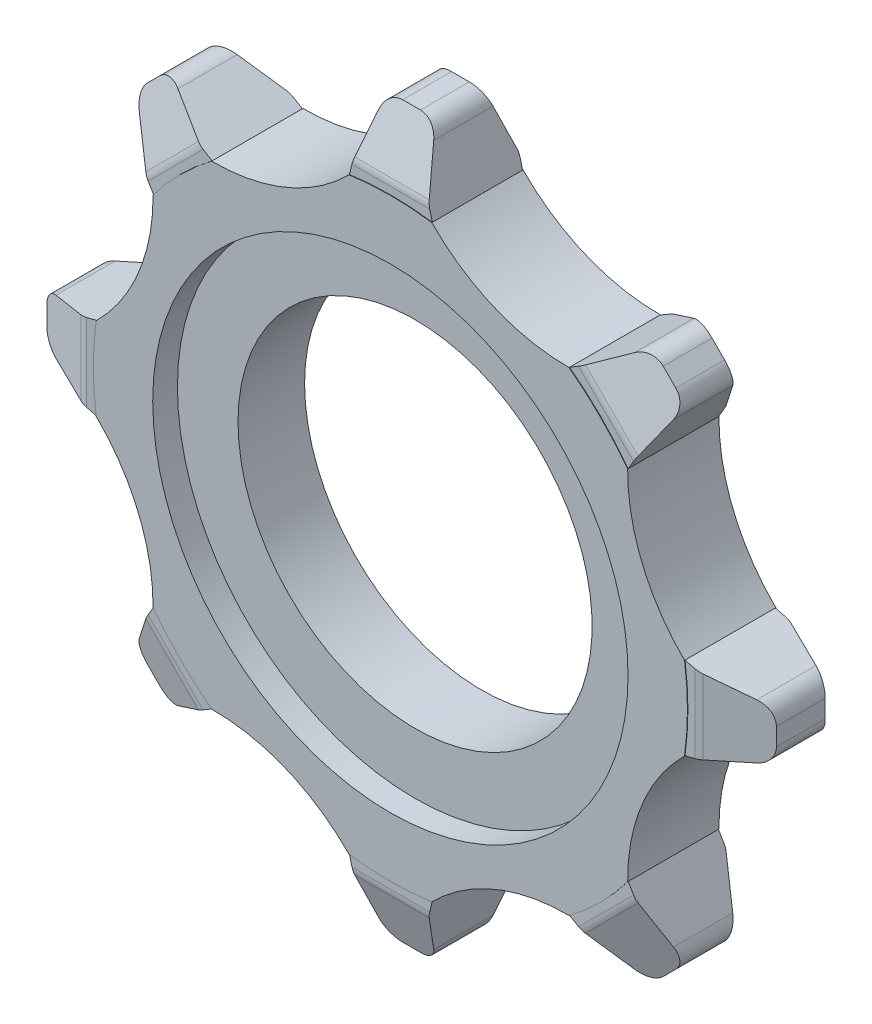
from build123d import *

# Parameters (mm, degrees)
SKETCH1_R           = 31.25
BOSS_EXTRUDE1_DEPTH = 15
BOSS_EXTRUDE2_DEPTH = 4.75
CHAMFER1_SIZE       = 6
CHAMFER1_SIZE2      = 2.183821406
CHAMFER2_SIZE       = 6
CHAMFER2_SIZE2      = 2.183821406
FILLET11_R          = 2
FILLET12_R          = 2
CIRPATTERN1_COUNT   = 8
SKETCH14_W          = 114.781544729
SKETCH14_H          = 99.982125168
CUT_EXTRUDE11_DEPTH = 20
SKETCH15_W          = 194.409122682
SKETCH15_H          = 129.478767366
CUT_EXTRUDE12_DEPTH = 20
CUT_EXTRUDE13_DEPTH = 20
CIRPATTERN3_COUNT   = 8
SKETCH20_R          = 18.625
CUT_EXTRUDE14_DEPTH = 20
SKETCH21_R          = 25
CUT_EXTRUDE15_DEPTH = 2.6


with BuildPart() as part:
    # Sketch1 → Boss-Extrude1 (new body, symmetric)
    with BuildSketch(Plane.XY):
        Circle(SKETCH1_R)
    extrude(amount=BOSS_EXTRUDE1_DEPTH, both=True)

    # Sketch2 → Boss-Extrude2 (add, symmetric)
    with BuildSketch(Plane.XY):
        Polygon((-28.372098708, -5), (-28.372098708, 5), (-38.372098708, 2.5), (-38.372098708, -2.5), align=None)
    extrude(amount=BOSS_EXTRUDE2_DEPTH, both=True)

    # Chamfer1
    chamfer1_edges = [part.edges().sort_by_distance(p)[0] for p in [
        (-38.372098708, 0, -4.75),
    ]]
    chamfer1_side = [part.faces().sort_by_distance(p)[0] for p in [
        (-34.440800156, 0, -4.75),
    ]]
    chamfer(chamfer1_edges, length=CHAMFER1_SIZE, length2=CHAMFER1_SIZE2, reference=chamfer1_side[0])

    # Chamfer2
    chamfer2_edges = [part.edges().sort_by_distance(p)[0] for p in [
        (-38.372098708, 0, 4.75),
    ]]
    chamfer2_side = [part.faces().sort_by_distance(p)[0] for p in [
        (-34.440800156, 0, 4.75),
    ]]
    chamfer(chamfer2_edges, length=CHAMFER2_SIZE, length2=CHAMFER2_SIZE2, reference=chamfer2_side[0])

    # Fillet11
    fillet11_edges = [part.edges().sort_by_distance(p)[0] for p in [
        (-38.372098708, -2.5, 0),
        (-38.372098708, 2.5, 0),
    ]]
    fillet(fillet11_edges, radius=FILLET11_R)

    # Fillet12
    fillet12_edges = [part.edges().sort_by_distance(p)[0] for p in [
        (-32.372098708, 0, -4.75),
        (-32.372098708, 0, 4.75),
    ]]
    fillet(fillet12_edges, radius=FILLET12_R)

    # CirPattern1: part ×8 about axis
    cirpattern1_axis = Axis((0, 0, 0), (0, 0, 1))


with BuildPart() as part_1:
    add(part.part)
    for i in range(1, CIRPATTERN1_COUNT):
        add(part.part.rotate(cirpattern1_axis, i * 360 / CIRPATTERN1_COUNT))

    # Sketch14 → Cut-Extrude11 (cut)
    with BuildSketch(Plane(origin=(0, 0, -4.8), x_dir=(-1, 0, 0), z_dir=(0, 0, -1))):
        with Locations((10.903993862, -9.833989058)):
            Rectangle(SKETCH14_W, SKETCH14_H)
    extrude(amount=CUT_EXTRUDE11_DEPTH, mode=Mode.SUBTRACT)

    # Sketch15 → Cut-Extrude12 (cut)
    with BuildSketch(Plane.XY.offset(4.8)):
        with Locations((1.322307029, -4.255701029)):
            Rectangle(SKETCH15_W, SKETCH15_H)
    extrude(amount=CUT_EXTRUDE12_DEPTH, mode=Mode.SUBTRACT)

    # Sketch17 → Cut-Extrude13 (cut)
    with BuildSketch(Plane.XY.offset(4.8)):
        with BuildLine():
            Line((-3.917153419, 32.703485033), (-4.356824963, 30.944798856))
            ThreePointArc((-4.356824963, 30.944798856), (-10.969884461, 26.483643844), (-18.800536638, 24.962017589))
            Line((-18.800536638, 24.962017589), (-20.35501029, 25.89470178))
            Line((-20.35501029, 25.89470178), (-3.917153419, 32.703485033))
        make_face()
    cut_extrude13 = extrude(amount=-CUT_EXTRUDE13_DEPTH, mode=Mode.SUBTRACT)

    # CirPattern3: Cut-Extrude13 ×8 about axis
    cirpattern3_axis = Axis((0, 0, 0), (0, 0, 1))
    for i in range(1, CIRPATTERN3_COUNT):
        add(cut_extrude13.rotate(cirpattern3_axis, i * 360 / CIRPATTERN3_COUNT), mode=Mode.SUBTRACT)

    # Sketch20 → Cut-Extrude14 (cut)
    with BuildSketch(Plane.XY.offset(4.8)):
        Circle(SKETCH20_R)
    extrude(amount=-CUT_EXTRUDE14_DEPTH, mode=Mode.SUBTRACT)

    # Sketch21 → Cut-Extrude15 (cut)
    with BuildSketch(Plane.XY.offset(4.8)):
        Circle(SKETCH21_R)
    extrude(amount=-CUT_EXTRUDE15_DEPTH, mode=Mode.SUBTRACT)


solid = part_1.part
